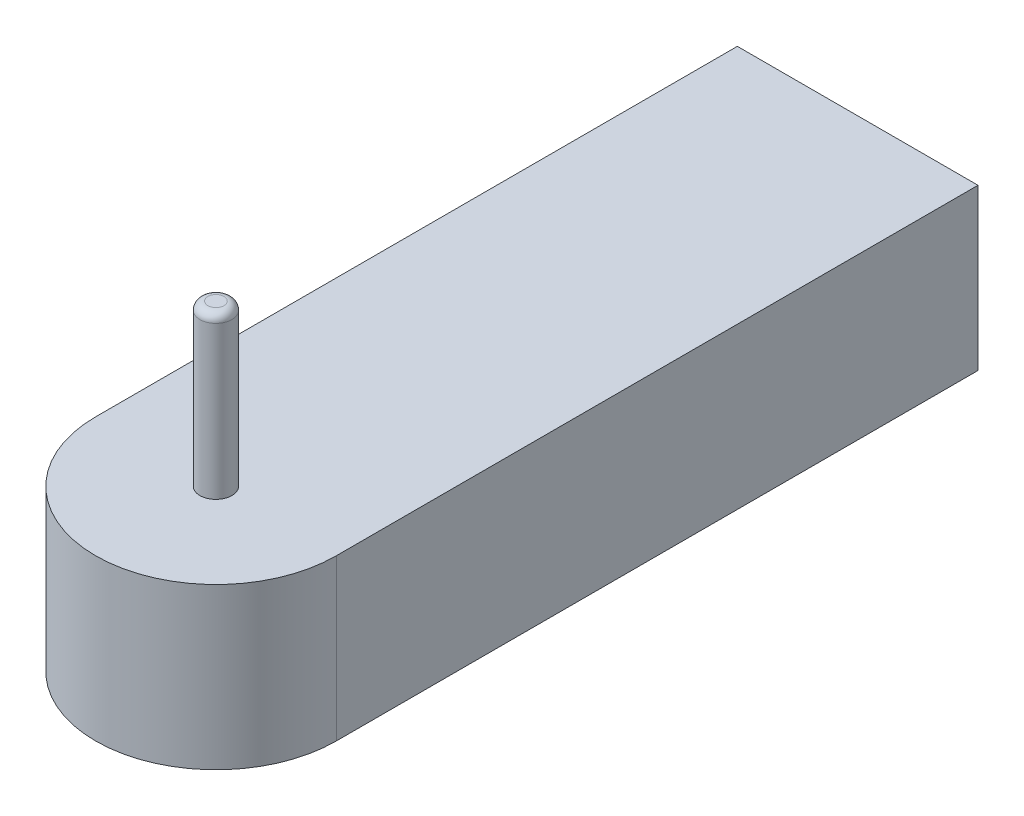
from build123d import *

# Parameters (mm, degrees)
EXTRUDE_1_DEPTH = 100
SKETCH_2_R      = 10
EXTRUDE_2_DEPTH = 100
FILLET_1_R      = 5


with BuildPart() as part:
    # 草图1 → 凸台-拉伸1 (new body)
    with BuildSketch(Plane(origin=(0, 0, 0), x_dir=(1, 0, 0), z_dir=(0, 1, 0))):
        with BuildLine():
            Line((0, 0), (150, 0))
            Line((150, 0), (150, -400))
            ThreePointArc((150, -400), (75, -475), (0, -400))
            Line((0, -400), (0, 0))
        make_face()
    extrude(amount=EXTRUDE_1_DEPTH)

    # 草图2 → 凸台-拉伸2 (add)
    with BuildSketch(Plane(origin=(0, 100, 0), x_dir=(1, 0, 0), z_dir=(0, 1, 0))):
        with Locations((75, -400)):
            Circle(SKETCH_2_R)
    extrude(amount=EXTRUDE_2_DEPTH)

    # 圆角1
    fillet_1_edges = [part.edges().sort_by_distance(p)[0] for p in [
        (65, 200, 400),
    ]]
    fillet(fillet_1_edges, radius=FILLET_1_R)


solid = part.part
